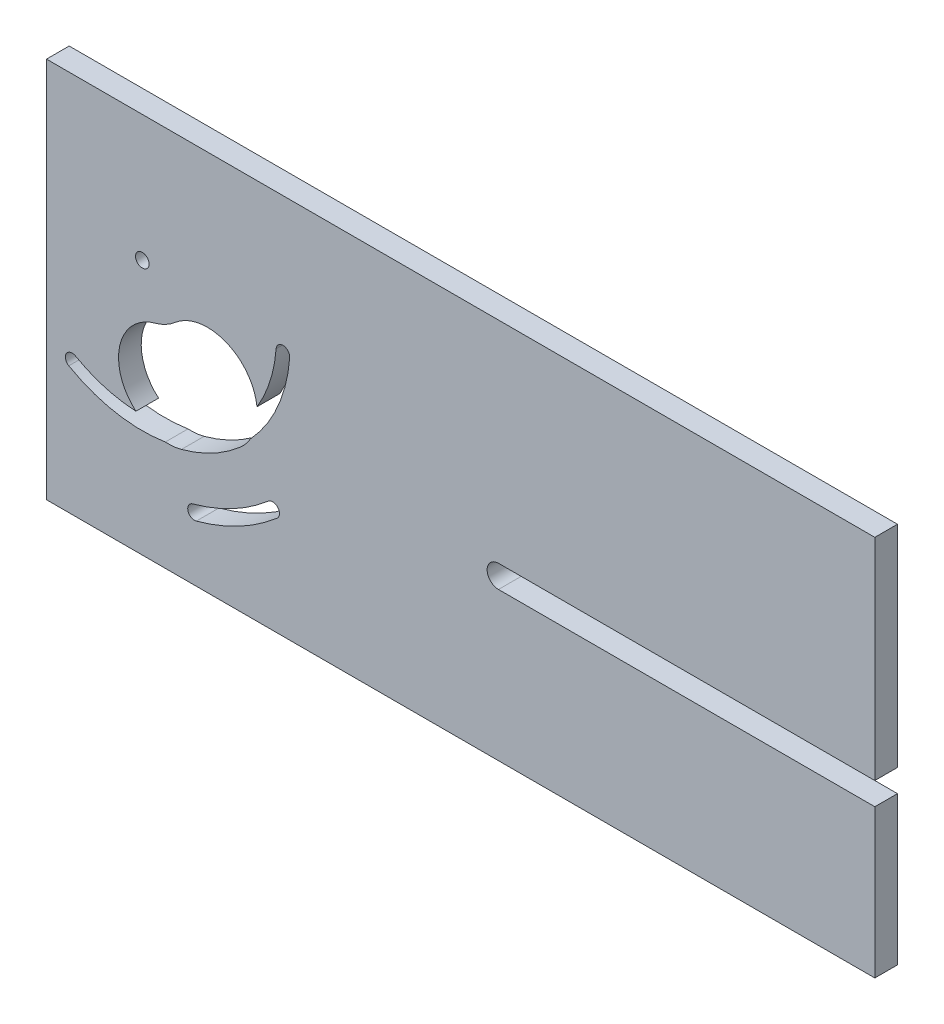
from build123d import *

# Parameters (mm, degrees)
SKETCH1_R           = 1.5
BOSS_EXTRUDE1_DEPTH = 5


with BuildPart() as part:
    # Sketch1 → Boss-Extrude1 (new body)
    with BuildSketch(Plane.XY):
        with BuildLine():
            Line((-91.35, 42.09), (-91.35, -42.09))
            Line((-91.35, -42.09), (91.35, -42.09))
            Line((91.35, -42.09), (91.35, -9.373756295))
            Line((91.35, -9.373756295), (8.343053199, -9.373756295))
            ThreePointArc((8.343053199, -9.373756295), (5.843053199, -6.873756295), (8.343053199, -4.373756295))
            Line((8.343053199, -4.373756295), (91.35, -4.373756295))
            Line((91.35, -4.373756295), (91.35, 42.09))
            Line((91.35, 42.09), (-91.35, 42.09))
        make_face()
        with BuildLine():
            ThreePointArc((-40.489979298, -20.16630551), (-48.867123378, -25.905481248), (-58.308825968, -29.642984865))
            ThreePointArc((-58.308825968, -29.642984865), (-60.149390448, -28.588317906), (-59.094723489, -26.747753426))
            ThreePointArc((-59.094723489, -26.747753426), (-50.275796541, -23.25677592), (-42.451209718, -17.896156784))
            ThreePointArc((-42.451209718, -17.896156784), (-40.846464239, -17.667243828), (-39.970594508, -19.031231147))
            ThreePointArc((-39.970594508, -19.031231147), (-40.106607189, -19.655361416), (-40.489979298, -20.16630551))
        make_face(mode=Mode.SUBTRACT)
        with BuildLine():
            ThreePointArc((-65.144358521, -17.951194504), (-76.122435192, -17.811173415), (-86.43146485, -14.034709351))
            ThreePointArc((-86.43146485, -14.034709351), (-86.987178316, -11.987471568), (-84.939940533, -11.431758101))
            ThreePointArc((-84.939940533, -11.431758101), (-78.516125038, -14.163976019), (-71.631092615, -15.315821832))
            ThreePointArc((-71.631092615, -15.315821832), (-75.191833702, -4.546421602), (-67.344295246, 3.643511155))
            ThreePointArc((-67.344295246, 3.643511155), (-65.062648548, 4.546702365), (-63.038259097, 5.933610208))
            ThreePointArc((-63.038259097, 5.933610208), (-51.860585441, 7.861943698), (-44.921737847, -1.110862578))
            ThreePointArc((-44.921737847, -1.110862578), (-42.027839791, 5.241756905), (-40.702136642, 12.095437041))
            ThreePointArc((-40.702136642, 12.095437041), (-39.151472366, 13.485222207), (-37.706118198, 11.986217927))
            ThreePointArc((-37.706118198, 11.986217927), (-37.707113918, 11.931572095), (-37.710099754, 11.876998812))
            ThreePointArc((-37.710099754, 11.876998812), (-40.341925186, 1.21814014), (-46.362913364, -7.96257196))
            ThreePointArc((-46.362913364, -7.96257196), (-47.396661948, -9.432315012), (-48.655902683, -10.714147119))
            ThreePointArc((-48.655902683, -10.714147119), (-54.732378683, -14.877136713), (-61.581046755, -17.588186064))
            ThreePointArc((-61.581046755, -17.588186064), (-63.34782833, -17.915697351), (-65.144358521, -17.951194504))
        make_face(mode=Mode.SUBTRACT)
        with Locations((-70.223567272, 14.250694236)):
            Circle(SKETCH1_R, mode=Mode.SUBTRACT)
    extrude(amount=BOSS_EXTRUDE1_DEPTH)


solid = part.part
